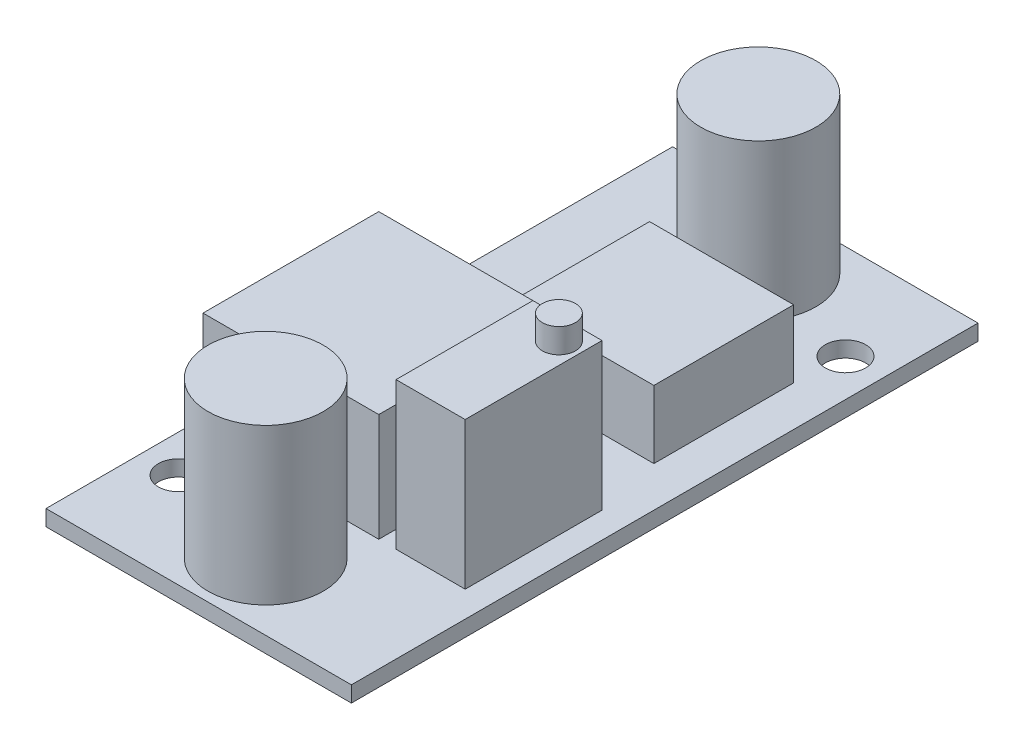
from build123d import *

# Parameters (mm, degrees)
SKETCH_1_W      = 21.2
SKETCH_1_H      = 43.5
SKETCH_1_R      = 1.4
EXTRUDE_1_DEPTH = 1.1
SKETCH_2_R      = 4
EXTRUDE_2_DEPTH = 10.8
SKETCH_3_W      = 12.2
SKETCH_3_H      = 12.2
EXTRUDE_3_DEPTH = 7.5
SKETCH_4_W      = 4.8
SKETCH_4_H      = 9.5
EXTRUDE_4_DEPTH = 10.2
SKETCH_5_W      = 10
SKETCH_5_H      = 9.7
EXTRUDE_5_DEPTH = 4.7
SKETCH_6_R      = 1.15
EXTRUDE_6_DEPTH = 1.7


with BuildPart() as part:
    # 草图1 → 凸台-拉伸1 (new body)
    with BuildSketch(Plane(origin=(0, 0, 0), x_dir=(1, 0, 0), z_dir=(0, 1, 0))):
        Rectangle(SKETCH_1_W, SKETCH_1_H)
        with Locations((8, 15.15)):
            Circle(SKETCH_1_R, mode=Mode.SUBTRACT)
        with Locations((-8, -15.15)):
            Circle(SKETCH_1_R, mode=Mode.SUBTRACT)
    extrude(amount=EXTRUDE_1_DEPTH)

    # 草图2 → 凸台-拉伸2 (add)
    with BuildSketch(Plane(origin=(0, 1.1, 0), x_dir=(1, 0, 0), z_dir=(0, 1, 0))):
        with Locations((0, 17.1)):
            Circle(SKETCH_2_R)
        with Locations((0, -17.1)):
            Circle(SKETCH_2_R)
    extrude(amount=EXTRUDE_2_DEPTH)

    # 草图3 → 凸台-拉伸3 (add)
    with BuildSketch(Plane(origin=(0, 1.1, 0), x_dir=(1, 0, 0), z_dir=(0, 1, 0))):
        with Locations((-3.3, -5.95)):
            Rectangle(SKETCH_3_W, SKETCH_3_H)
    extrude(amount=EXTRUDE_3_DEPTH)

    # 草图4 → 凸台-拉伸4 (add)
    with BuildSketch(Plane(origin=(0, 1.1, 0), x_dir=(1, 0, 0), z_dir=(0, 1, 0))):
        with Locations((6.4, -7.3)):
            Rectangle(SKETCH_4_W, SKETCH_4_H)
    extrude(amount=EXTRUDE_4_DEPTH)

    # 草图5 → 凸台-拉伸5 (add)
    with BuildSketch(Plane(origin=(0, 1.1, 0), x_dir=(1, 0, 0), z_dir=(0, 1, 0))):
        with Locations((2.8, 6.9)):
            Rectangle(SKETCH_5_W, SKETCH_5_H)
    extrude(amount=EXTRUDE_5_DEPTH)

    # 草图6 → 凸台-拉伸6 (add)
    with BuildSketch(Plane(origin=(0, 11.3, 0), x_dir=(1, 0, 0), z_dir=(0, 1, 0))):
        with Locations((7.351662329, -4.096039532)):
            Circle(SKETCH_6_R)
    extrude(amount=EXTRUDE_6_DEPTH)


solid = part.part
